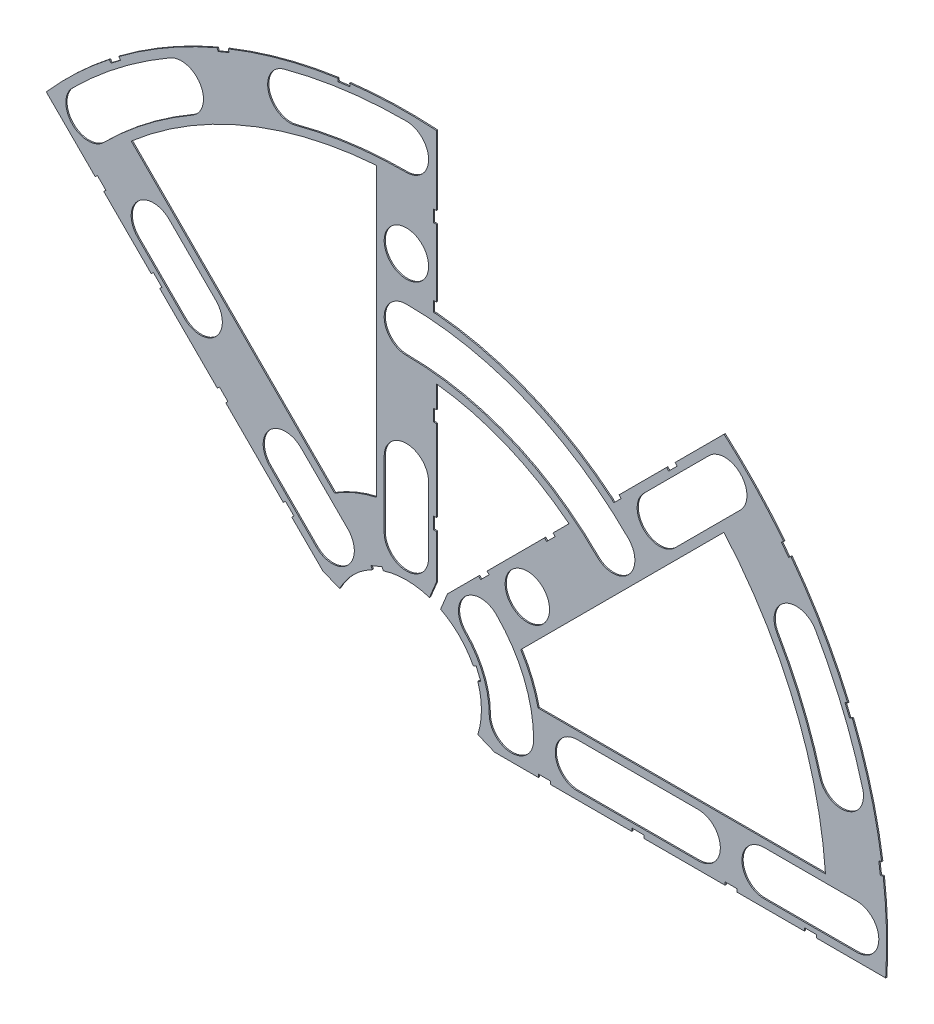
from build123d import *

# Parameters (mm, degrees)
BOSS_EXTRUDE1_DEPTH = 0.254
SKETCH2_R           = 4.699
CUT_EXTRUDE1_DEPTH  = 1.254
SKETCH3_W           = 2.54
SKETCH3_H           = 0.635
SKETCH3_W_2         = 0.635
SKETCH3_H_2         = 2.201822509
SKETCH3_H_3         = 2.54
CUT_EXTRUDE2_DEPTH  = 1.254
CUT_EXTRUDE3_DEPTH  = 1.254


with BuildPart() as part:
    # Sketch1 → Boss-Extrude1 (new body)
    with BuildSketch(Plane.XY):
        with BuildLine():
            Line((8.696654013, 17.676910134), (34.405475059, 43.38573118))
            ThreePointArc((34.405475059, 43.38573118), (21.189947017, 51.157057474), (6.35, 55.006689448))
            Line((6.35, 55.006689448), (6.35, 18.648926052))
            Line((6.35, 18.648926052), (4.88230096, 15.105587123))
            ThreePointArc((4.88230096, 15.105587123), (-6.075099489, 14.666587579), (-14.133571205, 7.228954972))
            Line((-14.133571205, 7.228954972), (-17.676910134, 8.696654013))
            Line((-17.676910134, 8.696654013), (-76.191723231, 67.21146711))
            ThreePointArc((-76.191723231, 67.21146711), (-38.880636728, 93.866160503), (6.35, 101.401368334))
            Line((6.35, 101.401368334), (6.35, 67.775177491))
            ThreePointArc((6.35, 67.775177491), (26.050026608, 62.890327537), (43.43415954, 52.414415661))
            Line((43.43415954, 52.414415661), (67.21146711, 76.191723231))
            ThreePointArc((67.21146711, 76.191723231), (93.866160503, 38.880636728), (101.401368334, -6.35))
            Line((101.401368334, -6.35), (18.648926052, -6.35))
            Line((18.648926052, -6.35), (15.105587123, -4.88230096))
            ThreePointArc((15.105587123, -4.88230096), (14.666587579, 6.075099489), (7.228954972, 14.133571205))
            Line((7.228954972, 14.133571205), (8.696654013, 17.676910134))
        make_face()
        with BuildLine():
            Line((88.672924278, 6.35), (27.86051193, 6.35))
            ThreePointArc((27.86051193, 6.35), (26.399857642, 10.93517908), (24.190484974, 15.210228852))
            Line((24.190484974, 15.210228852), (67.191354125, 58.211098004))
            ThreePointArc((67.191354125, 58.211098004), (82.13289044, 34.020557137), (88.672924278, 6.35))
        make_face(mode=Mode.SUBTRACT)
        with BuildLine():
            Line((-58.211098004, 67.191354125), (-15.210228852, 24.190484974))
            ThreePointArc((-15.210228852, 24.190484974), (-10.93517908, 26.399857642), (-6.35, 27.86051193))
            Line((-6.35, 27.86051193), (-6.35, 88.672924278))
            ThreePointArc((-6.35, 88.672924278), (-34.020557137, 82.13289044), (-58.211098004, 67.191354125))
        make_face(mode=Mode.SUBTRACT)
    extrude(amount=BOSS_EXTRUDE1_DEPTH)

    # Sketch2 → Cut-Extrude1 (cut, through all)
    with BuildSketch(Plane.XY.offset(0.254)):
        with Locations((22.225, 0)):
            Circle(SKETCH2_R)
        with Locations((36.195, 0)):
            Circle(SKETCH2_R)
        with Locations((61.722, 0)):
            Circle(SKETCH2_R)
        with Locations((75.692, 0)):
            Circle(SKETCH2_R)
        with Locations((95.25, 0)):
            Circle(SKETCH2_R)
        with Locations((15.715448212, 15.715448212)):
            Circle(SKETCH2_R)
        with Locations((25.593729945, 25.593729945)):
            Circle(SKETCH2_R)
        with Locations((43.644044748, 43.644044748)):
            Circle(SKETCH2_R)
        with Locations((53.522326482, 53.522326482)):
            Circle(SKETCH2_R)
        with Locations((92.004434954, 24.652514046)):
            Circle(SKETCH2_R)
        with Locations((82.48891971, 47.625)):
            Circle(SKETCH2_R)
        with Locations((67.351920908, 67.351920908)):
            Circle(SKETCH2_R)
        with Locations((0, 95.25)):
            Circle(SKETCH2_R)
        with Locations((0, 75.692)):
            Circle(SKETCH2_R)
        with Locations((-53.522326482, 53.522326482)):
            Circle(SKETCH2_R)
        with Locations((-43.644044748, 43.644044748)):
            Circle(SKETCH2_R)
        with Locations((0, 61.722)):
            Circle(SKETCH2_R)
        with Locations((0, 36.195)):
            Circle(SKETCH2_R)
        with Locations((-25.593729945, 25.593729945)):
            Circle(SKETCH2_R)
        with Locations((-15.715448212, 15.715448212)):
            Circle(SKETCH2_R)
        with Locations((0, 22.225)):
            Circle(SKETCH2_R)
        with Locations((-24.652514046, 92.004434954)):
            Circle(SKETCH2_R)
        with Locations((-47.625, 82.48891971)):
            Circle(SKETCH2_R)
        with Locations((-67.351920908, 67.351920908)):
            Circle(SKETCH2_R)
    extrude(amount=-CUT_EXTRUDE1_DEPTH, mode=Mode.SUBTRACT)

    # Sketch3 → Cut-Extrude2 (cut, through all)
    with BuildSketch(Plane.XY.offset(0.254)):
        Polygon((15.266435406, 24.246691527), (17.06248663, 26.042742751), (17.511499436, 25.593729945), (15.715448212, 23.797678721), align=None)
        Polygon((55.048970022, 64.029226143), (56.845021246, 65.825277367), (57.294034052, 65.376264561), (55.497982828, 63.580213337), align=None)
        Polygon((29.230733674, 38.210989795), (31.026784898, 40.007041019), (31.475797704, 39.558028213), (29.67974648, 37.761976989), align=None)
        with Locations((29.21, -6.0325)):
            Rectangle(SKETCH3_W, SKETCH3_H)
        with Locations((68.707, -6.0325)):
            Rectangle(SKETCH3_W, SKETCH3_H)
        Polygon((43.43415954, 52.414415661), (44.991083167, 53.971339288), (45.440095973, 53.522326482), (43.883172346, 51.965402855), align=None)
        with Locations((48.9585, -6.0325)):
            Rectangle(SKETCH3_W, SKETCH3_H)
        with Locations((85.471, -6.0325)):
            Rectangle(SKETCH3_W, SKETCH3_H)
        Polygon((99.935462164, 14.437711971), (100.266998693, 11.919442024), (101.526133667, 12.085210288), (101.194597138, 14.603480236), align=None)
        Polygon((93.765504959, 37.464305742), (94.938831965, 37.950313702), (93.966816047, 40.296967714), (92.793489041, 39.810959755), align=None)
        Polygon((79.327792988, 62.471156422), (80.874047017, 60.456038938), (81.88160576, 61.229165953), (80.33535173, 63.244283437), align=None)
        Polygon((13.593916116, 7.005422516), (14.565932035, 4.658768503), (15.739259041, 5.144776462), (14.767243123, 7.491430475), align=None)
        with Locations((6.0325, 68.876088745)):
            Rectangle(SKETCH3_W_2, SKETCH3_H_2)
        Polygon((-40.007041019, 31.026784898), (-38.210989795, 29.230733674), (-37.761976989, 29.67974648), (-39.558028213, 31.475797704), align=None)
        Polygon((-26.042742751, 17.06248663), (-25.593729945, 17.511499436), (-23.797678721, 15.715448212), (-24.246691527, 15.266435406), align=None)
        Polygon((-65.825277367, 56.845021246), (-64.029226143, 55.048970022), (-63.580213337, 55.497982828), (-65.376264561, 57.294034052), align=None)
        Polygon((-63.244283437, 80.33535173), (-61.229165953, 81.88160576), (-60.456038938, 80.874047017), (-62.471156422, 79.327792988), align=None)
        Polygon((-37.950313702, 94.938831965), (-40.296967714, 93.966816047), (-39.810959755, 92.793489041), (-37.464305742, 93.765504959), align=None)
        Polygon((-14.437711971, 99.935462165), (-14.603480236, 101.194597138), (-12.085210288, 101.526133667), (-11.919442024, 100.266998693), align=None)
        with Locations((6.0325, 85.471)):
            Rectangle(SKETCH3_W_2, SKETCH3_H_3)
        with Locations((6.0325, 48.9585)):
            Rectangle(SKETCH3_W_2, SKETCH3_H_3)
        with Locations((6.0325, 29.21)):
            Rectangle(SKETCH3_W_2, SKETCH3_H_3)
        Polygon((-7.491430475, 14.767243123), (-5.144776462, 15.739259041), (-4.658768503, 14.565932035), (-7.005422516, 13.593916116), align=None)
        Polygon((-53.971339288, 44.991083167), (-52.175288063, 43.195031942), (-51.726275257, 43.644044748), (-53.522326482, 45.440095973), align=None)
    extrude(amount=-CUT_EXTRUDE2_DEPTH, mode=Mode.SUBTRACT)

    # Sketch4 → Cut-Extrude3 (cut, through all)
    with BuildSketch(Plane.XY.offset(0.254)):
        with BuildLine():
            Line((-4.699, 22.225), (-4.699, 36.195))
            ThreePointArc((-4.699, 36.195), (0, 40.894), (4.699, 36.195))
            Line((4.699, 36.195), (4.699, 22.225))
            ThreePointArc((4.699, 22.225), (0, 17.526), (-4.699, 22.225))
        make_face()
        with BuildLine():
            Line((-19.038142977, 12.392753447), (-28.91642471, 22.27103518))
            ThreePointArc((-28.91642471, 22.27103518), (-28.91642471, 28.91642471), (-22.27103518, 28.91642471))
            Line((-22.27103518, 28.91642471), (-12.392753447, 19.038142977))
            ThreePointArc((-12.392753447, 19.038142977), (-12.392753447, 12.392753447), (-19.038142977, 12.392753447))
        make_face()
        with BuildLine():
            Line((-46.966739513, 40.321349984), (-56.845021246, 50.199631717))
            ThreePointArc((-56.845021246, 50.199631717), (-56.845021246, 56.845021246), (-50.199631717, 56.845021246))
            Line((-50.199631717, 56.845021246), (-40.321349984, 46.966739513))
            ThreePointArc((-40.321349984, 46.966739513), (-40.321349984, 40.321349984), (-46.966739513, 40.321349984))
        make_face()
        with BuildLine():
            Line((36.195, 4.699), (61.722, 4.699))
            ThreePointArc((61.722, 4.699), (66.421, 0), (61.722, -4.699))
            Line((61.722, -4.699), (36.195, -4.699))
            ThreePointArc((36.195, -4.699), (31.496, 0), (36.195, 4.699))
        make_face()
        with BuildLine():
            Line((75.692, 4.699), (95.25, 4.699))
            ThreePointArc((95.25, 4.699), (99.949, 0), (95.25, -4.699))
            Line((95.25, -4.699), (75.692, -4.699))
            ThreePointArc((75.692, -4.699), (70.993, 0), (75.692, 4.699))
        make_face()
        with BuildLine():
            Line((50.199631717, 56.845021246), (64.029226143, 70.674615673))
            ThreePointArc((64.029226143, 70.674615673), (70.674615673, 70.674615673), (70.674615673, 64.029226143))
            Line((70.674615673, 64.029226143), (56.845021246, 50.199631717))
            ThreePointArc((56.845021246, 50.199631717), (50.199631717, 50.199631717), (50.199631717, 56.845021246))
        make_face()
        with BuildLine():
            ThreePointArc((46.966739513, 46.966739513), (25.418216261, 61.365002429), (0, 66.421))
            ThreePointArc((0, 66.421), (-4.699, 61.722), (0, 57.023))
            ThreePointArc((0, 57.023), (21.821757364, 52.682382582), (40.321349984, 40.321349984))
            ThreePointArc((40.321349984, 40.321349984), (46.966739513, 40.321349984), (46.966739513, 46.966739513))
        make_face()
        with BuildLine():
            ThreePointArc((26.924, 0), (24.874532533, 10.303368733), (19.038142977, 19.038142977))
            ThreePointArc((19.038142977, 19.038142977), (12.392753447, 19.038142977), (12.392753447, 12.392753447))
            ThreePointArc((12.392753447, 12.392753447), (16.191912687, 6.706909836), (17.526, 0))
            ThreePointArc((17.526, 0), (22.225, -4.699), (26.924, 0))
        make_face()
        with BuildLine():
            ThreePointArc((96.543320412, 25.868704739), (92.340835395, 38.248826381), (86.558373083, 49.9745))
            ThreePointArc((86.558373083, 49.9745), (80.13941971, 51.694453372), (78.419466338, 45.2755))
            ThreePointArc((78.419466338, 45.2755), (83.658215548, 34.652367484), (87.465549496, 23.436323353))
            ThreePointArc((87.465549496, 23.436323353), (93.220625647, 20.113628588), (96.543320412, 25.868704739))
        make_face()
        with BuildLine():
            ThreePointArc((0, 99.949), (-13.045962386, 99.093922449), (-25.868704739, 96.543320412))
            ThreePointArc((-25.868704739, 96.543320412), (-29.191399504, 90.788244261), (-23.436323353, 87.465549496))
            ThreePointArc((-23.436323353, 87.465549496), (-11.819277232, 89.776323642), (0, 90.551))
            ThreePointArc((0, 90.551), (4.699, 95.25), (0, 99.949))
        make_face()
        with BuildLine():
            ThreePointArc((-49.9745, 86.558373083), (-60.845096068, 79.294873009), (-70.674615673, 70.674615673))
            ThreePointArc((-70.674615673, 70.674615673), (-70.674615673, 64.029226143), (-64.029226143, 64.029226143))
            ThreePointArc((-64.029226143, 64.029226143), (-55.123956158, 71.838938317), (-45.2755, 78.419466338))
            ThreePointArc((-45.2755, 78.419466338), (-43.555546628, 84.83841971), (-49.9745, 86.558373083))
        make_face()
    extrude(amount=-CUT_EXTRUDE3_DEPTH, mode=Mode.SUBTRACT)


solid = part.part
